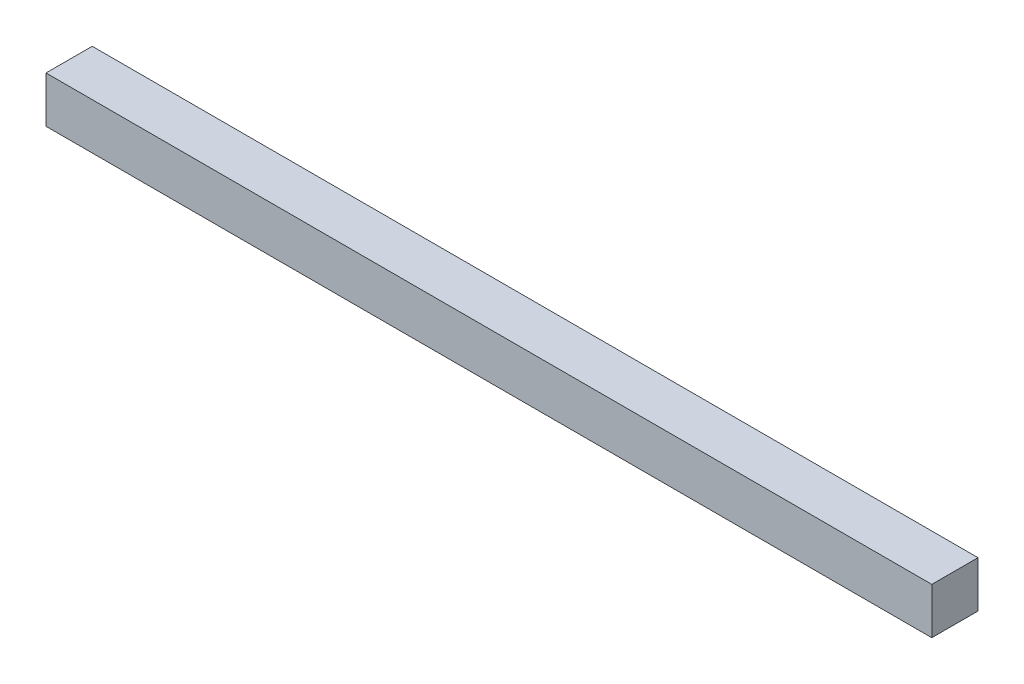
from build123d import *

# Parameters (mm, degrees)
SKETCH1_W           = 11.5
SKETCH1_H           = 0.6
BOSS_EXTRUDE2_DEPTH = 0.3


with BuildPart() as part:
    # Sketch1 → Boss-Extrude2 (new body, symmetric)
    with BuildSketch(Plane(origin=(0, 0, 0), x_dir=(1, 0, 0), z_dir=(0, 1, 0))):
        Rectangle(SKETCH1_W, SKETCH1_H)
    extrude(amount=BOSS_EXTRUDE2_DEPTH, both=True)


solid = part.part
